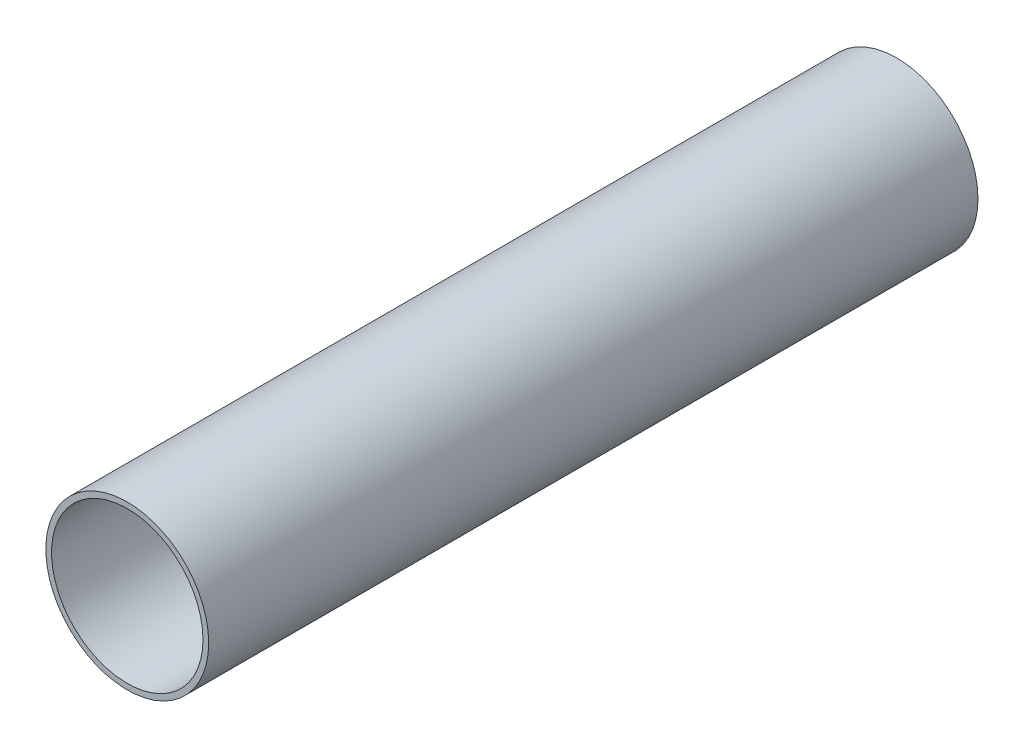
from build123d import *

# Parameters (mm, degrees)
ESBO_O1_R                = 28.575
ESBO_O1_R_2              = 26.575
RESSALTO_EXTRUS_O1_DEPTH = 270


with BuildPart() as part:
    # Esboço1 → Ressalto-extrusão1 (new body)
    with BuildSketch(Plane.XY):
        Circle(ESBO_O1_R)
        Circle(ESBO_O1_R_2, mode=Mode.SUBTRACT)
    extrude(amount=RESSALTO_EXTRUS_O1_DEPTH)


solid = part.part
